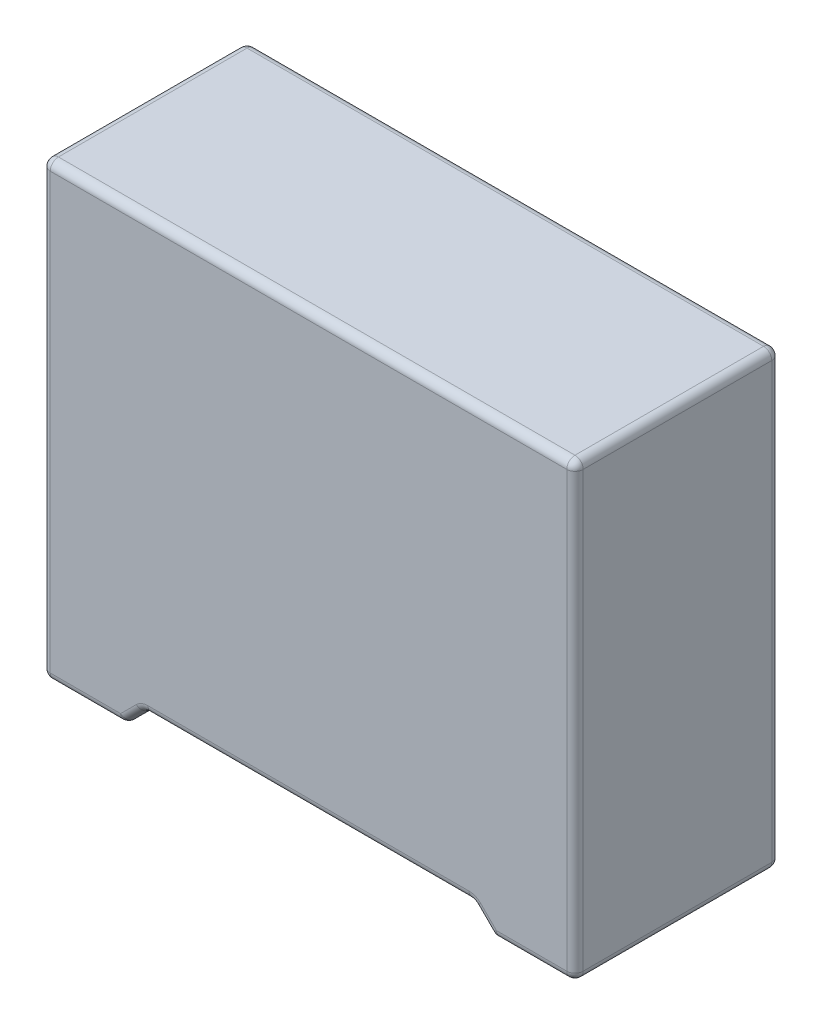
from build123d import *

# Parameters (mm, degrees)
SKETCH1_W           = 13
SKETCH1_H           = 5
BOSS_EXTRUDE1_DEPTH = 11
CUT_EXTRUDE1_DEPTH  = 6
FILLET1_R           = 0.2
SKETCH3_R           = 0.3


with BuildPart() as part:
    # Sketch1 → Boss-Extrude1 (new body)
    with BuildSketch(Plane(origin=(0, 0, 0), x_dir=(1, 0, 0), z_dir=(0, 1, 0))):
        Rectangle(SKETCH1_W, SKETCH1_H)
    extrude(amount=BOSS_EXTRUDE1_DEPTH)

    # Sketch2 → Cut-Extrude1 (cut, through all)
    with BuildSketch(Plane.XY.offset(2.5)):
        Polygon((-4.5, 0), (-4, 0.5), (4, 0.5), (4.5, 0), (4.5, -1.5), (-4.5, -1.5), align=None)
    extrude(amount=-CUT_EXTRUDE1_DEPTH, mode=Mode.SUBTRACT)

    # Fillet1
    fillet1_edges = [part.edges().sort_by_distance(p)[0] for p in [
        (6.5, 11, 0),
        (0, 11, -2.5),
        (-5.5, 0, -2.5),
        (5.5, 0, 2.5),
        (4.25, 0.25, 2.5),
        (0, 0.5, 2.5),
        (-4.25, 0.25, 2.5),
        (-4.25, 0.25, -2.5),
        (-4.5, 0, 0),
        (0, 0.5, -2.5),
        (-4, 0.5, 0),
        (4.25, 0.25, -2.5),
        (4, 0.5, 0),
        (4.5, 0, 0),
        (-6.5, 11, 0),
        (5.5, 0, -2.5),
        (6.5, 0, 0),
        (-5.5, 0, 2.5),
        (-6.5, 0, 0),
        (0, 11, 2.5),
        (-6.5, 5.5, -2.5),
        (6.5, 5.5, -2.5),
        (6.5, 5.5, 2.5),
        (-6.5, 5.5, 2.5),
    ]]
    fillet(fillet1_edges, radius=FILLET1_R)

    # Sweep1: sweep along a path in Sketch5
    with BuildLine(Plane(origin=(-5, 0, 0), x_dir=(0, 0, -1), z_dir=(1, 0, 0))) as sweep1_path:
        Line((0, 0), (0, -0.1))
        ThreePointArc((0, -0.1), (0.146446609, -0.453553391), (0.5, -0.6))
        Line((0.5, -0.6), (3, -0.6))
    # Sketch3 → Sweep1 (sweep)
    with BuildSketch(Plane.XZ):
        with Locations((-5, 0)):
            Circle(SKETCH3_R)
    sweep1 = sweep(path=sweep1_path.line)

    # Mirror1: Sweep1 across plane
    add(sweep1.mirror(Plane(origin=(0, 0, 0), x_dir=(0, 0, 1), z_dir=(1, 0, 0))))


solid = part.part
